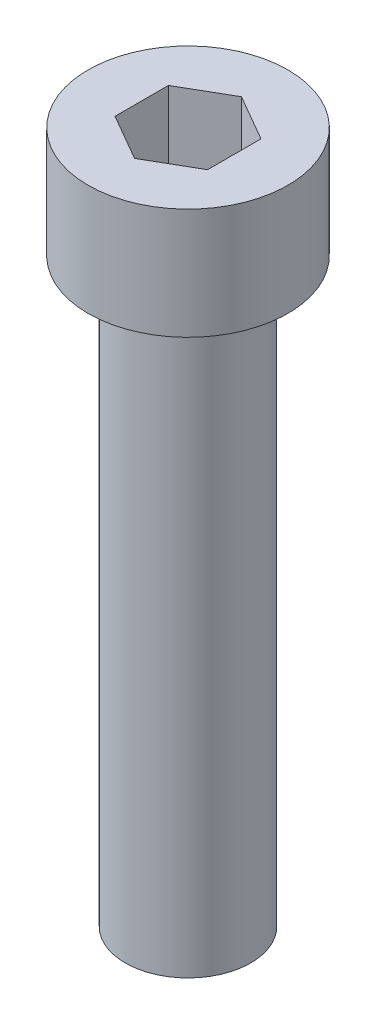
from build123d import *

# Parameters (mm, degrees)
SKETCH1_R           = 2.7
BOSS_EXTRUDE1_DEPTH = 3
SKETCH2_R           = 1.696293742
BOSS_EXTRUDE2_DEPTH = 15.7
CUT_EXTRUDE1_DEPTH  = 2


with BuildPart() as part:
    # Sketch1 → Boss-Extrude1 (new body)
    with BuildSketch(Plane(origin=(0, 0, 0), x_dir=(1, 0, 0), z_dir=(0, 1, 0))):
        with Locations((184.714490272, -125.24429514)):
            Circle(SKETCH1_R)
    extrude(amount=-BOSS_EXTRUDE1_DEPTH)

    # Sketch2 → Boss-Extrude2 (add)
    with BuildSketch(Plane.XZ.offset(3)):
        with Locations((184.714490272, 125.24429514)):
            Circle(SKETCH2_R)
    extrude(amount=BOSS_EXTRUDE2_DEPTH)

    # Sketch3 → Cut-Extrude1 (cut)
    with BuildSketch(Plane(origin=(0, 0, 0), x_dir=(1, 0, 0), z_dir=(0, 1, 0))):
        Polygon((184.714490272, -123.800919467), (183.464490272, -124.522607304), (183.464490272, -125.965982977), (184.714490272, -126.687670813), (185.964490272, -125.965982977), (185.964490272, -124.522607304), align=None)
    extrude(amount=-CUT_EXTRUDE1_DEPTH, mode=Mode.SUBTRACT)


solid = part.part
